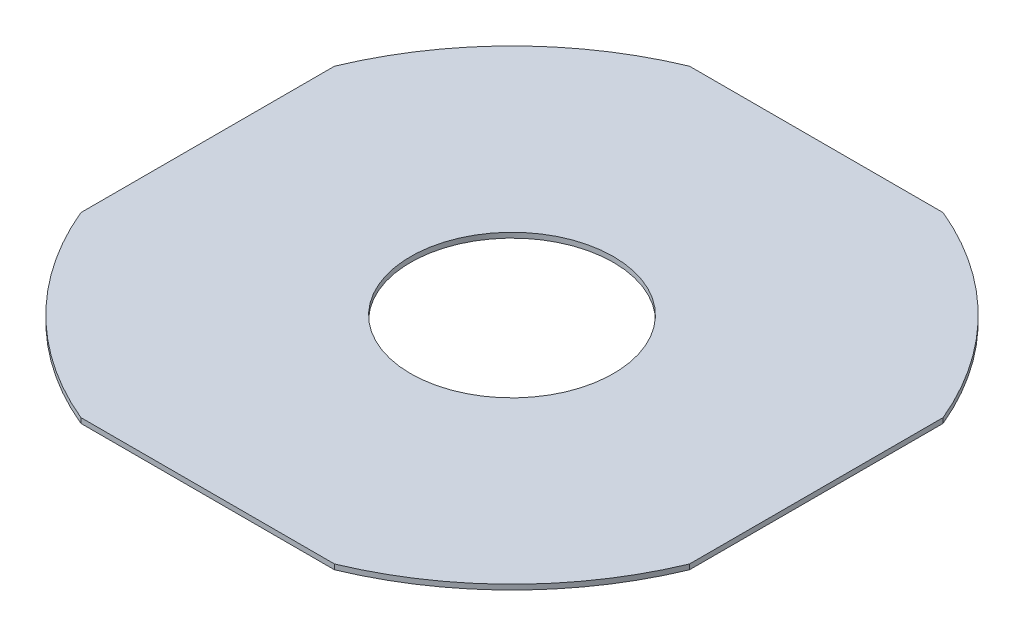
from build123d import *

# Parameters (mm, degrees)
SKETCH1_W           = 1200
SKETCH1_H           = 1200
BOSS_EXTRUDE1_DEPTH = 10
SKETCH2_R           = 200
CUT_EXTRUDE1_DEPTH  = 11
SKETCH3_R           = 1053.62312192
SKETCH3_R_2         = 650
CUT_EXTRUDE2_DEPTH  = 11


with BuildPart() as part:
    # Sketch1 → Boss-Extrude1 (new body)
    with BuildSketch(Plane(origin=(0, 0, 0), x_dir=(1, 0, 0), z_dir=(0, 1, 0))):
        Rectangle(SKETCH1_W, SKETCH1_H)
    extrude(amount=BOSS_EXTRUDE1_DEPTH)

    # Sketch2 → Cut-Extrude1 (cut, through all)
    with BuildSketch(Plane(origin=(0, 10, 0), x_dir=(1, 0, 0), z_dir=(0, 1, 0))):
        Circle(SKETCH2_R)
    extrude(amount=-CUT_EXTRUDE1_DEPTH, mode=Mode.SUBTRACT)

    # Sketch3 → Cut-Extrude2 (cut, through all)
    with BuildSketch(Plane(origin=(0, 10, 0), x_dir=(1, 0, 0), z_dir=(0, 1, 0))):
        Circle(SKETCH3_R)
        Circle(SKETCH3_R_2, mode=Mode.SUBTRACT)
    extrude(amount=-CUT_EXTRUDE2_DEPTH, mode=Mode.SUBTRACT)


solid = part.part
